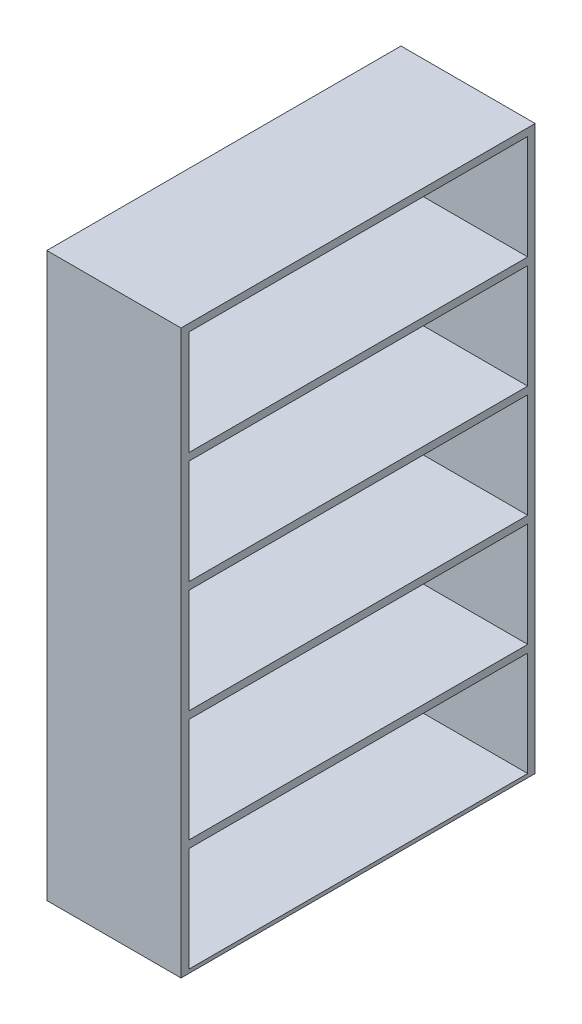
from build123d import *

# Parameters (mm, degrees)
SKETCH1_W           = 457.2
SKETCH1_H           = 1206.5
BOSS_EXTRUDE1_DEPTH = 1917.7
SKETCH2_W           = 1153.16
SKETCH2_H           = 355.6
CUT_EXTRUDE2_DEPTH  = 458.2


with BuildPart() as part:
    # Sketch1 → Boss-Extrude1 (new body)
    with BuildSketch(Plane(origin=(0, 0, 0), x_dir=(1, 0, 0), z_dir=(0, 1, 0))):
        Rectangle(SKETCH1_W, SKETCH1_H)
    extrude(amount=BOSS_EXTRUDE1_DEPTH)

    # Sketch2 → Cut-Extrude2 (cut, through all)
    with BuildSketch(Plane(origin=(228.6, 0, 0), x_dir=(0, 0, -1), z_dir=(1, 0, 0))):
        with Locations((1.27, 1714.5)):
            Rectangle(SKETCH2_W, SKETCH2_H)
        with Locations((1.27, 1333.5)):
            Rectangle(SKETCH2_W, SKETCH2_H)
        with Locations((1.27, 952.5)):
            Rectangle(SKETCH2_W, SKETCH2_H)
        with Locations((1.27, 571.5)):
            Rectangle(SKETCH2_W, SKETCH2_H)
        with Locations((1.27, 190.5)):
            Rectangle(SKETCH2_W, SKETCH2_H)
    extrude(amount=-CUT_EXTRUDE2_DEPTH, mode=Mode.SUBTRACT)


solid = part.part
